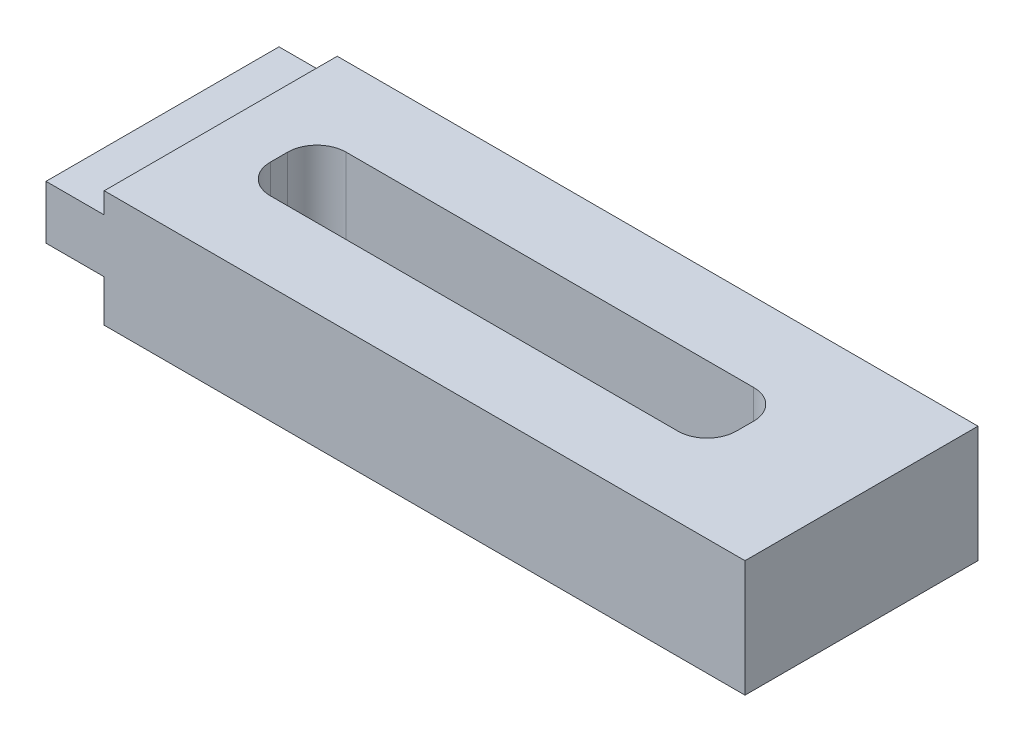
from build123d import *

# Parameters (mm, degrees)
SKETCH1_W           = 76.2
SKETCH1_H           = 25.4
BOSS_EXTRUDE1_DEPTH = 12.7
CUT_EXTRUDE1_DEPTH  = 13.7
SKETCH4_W           = 6.35
SKETCH4_H           = 4.572
SKETCH4_H_2         = 2.286
CUT_EXTRUDE2_DEPTH  = 26.4


with BuildPart() as part:
    # Sketch1 → Boss-Extrude1 (new body)
    with BuildSketch(Plane(origin=(0, 0, 0), x_dir=(1, 0, 0), z_dir=(0, 1, 0))):
        with Locations((38.1, 12.7)):
            Rectangle(SKETCH1_W, SKETCH1_H)
    extrude(amount=BOSS_EXTRUDE1_DEPTH)

    # Sketch3 → Cut-Extrude1 (cut, through all)
    with BuildSketch(Plane(origin=(0, 12.7, 0), x_dir=(1, 0, 0), z_dir=(0, 1, 0))):
        with BuildLine():
            Line((15.875, 8.5725), (60.325, 8.5725))
            ThreePointArc((60.325, 8.5725), (62.57006403, 9.50243597), (63.5, 11.7475))
            Line((63.5, 11.7475), (63.5, 13.6525))
            ThreePointArc((63.5, 13.6525), (62.57006403, 15.89756403), (60.325, 16.8275))
            Line((60.325, 16.8275), (15.875, 16.8275))
            ThreePointArc((15.875, 16.8275), (13.62993597, 15.89756403), (12.7, 13.6525))
            Line((12.7, 13.6525), (12.7, 11.7475))
            ThreePointArc((12.7, 11.7475), (13.62993597, 9.50243597), (15.875, 8.5725))
        make_face()
    extrude(amount=-CUT_EXTRUDE1_DEPTH, mode=Mode.SUBTRACT)

    # Sketch4 → Cut-Extrude2 (cut, through all)
    with BuildSketch(Plane.XY):
        with Locations((3.175, 2.286)):
            Rectangle(SKETCH4_W, SKETCH4_H)
        with Locations((3.175, 11.557)):
            Rectangle(SKETCH4_W, SKETCH4_H_2)
    extrude(amount=-CUT_EXTRUDE2_DEPTH, mode=Mode.SUBTRACT)


solid = part.part
